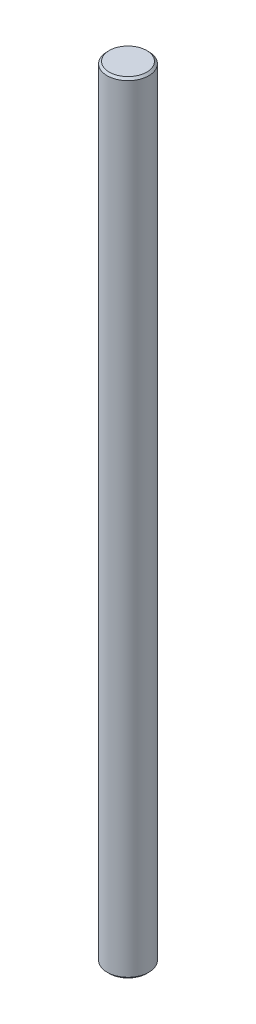
from build123d import *

# Parameters (mm, degrees)
SKETCH1_R           = 2
BOSS_EXTRUDE1_DEPTH = 37.5
CHAMFER1_SIZE       = 0.2


with BuildPart() as part:
    # Sketch1 → Boss-Extrude1 (new body, symmetric)
    with BuildSketch(Plane(origin=(0, 0, 0), x_dir=(1, 0, 0), z_dir=(0, 1, 0))):
        Circle(SKETCH1_R)
    extrude(amount=BOSS_EXTRUDE1_DEPTH, both=True)

    # Chamfer1
    chamfer1_edges = [part.edges().sort_by_distance(p)[0] for p in [
        (-2, -37.5, 0),
        (-2, 37.5, 0),
    ]]
    chamfer(chamfer1_edges, length=CHAMFER1_SIZE)


solid = part.part
